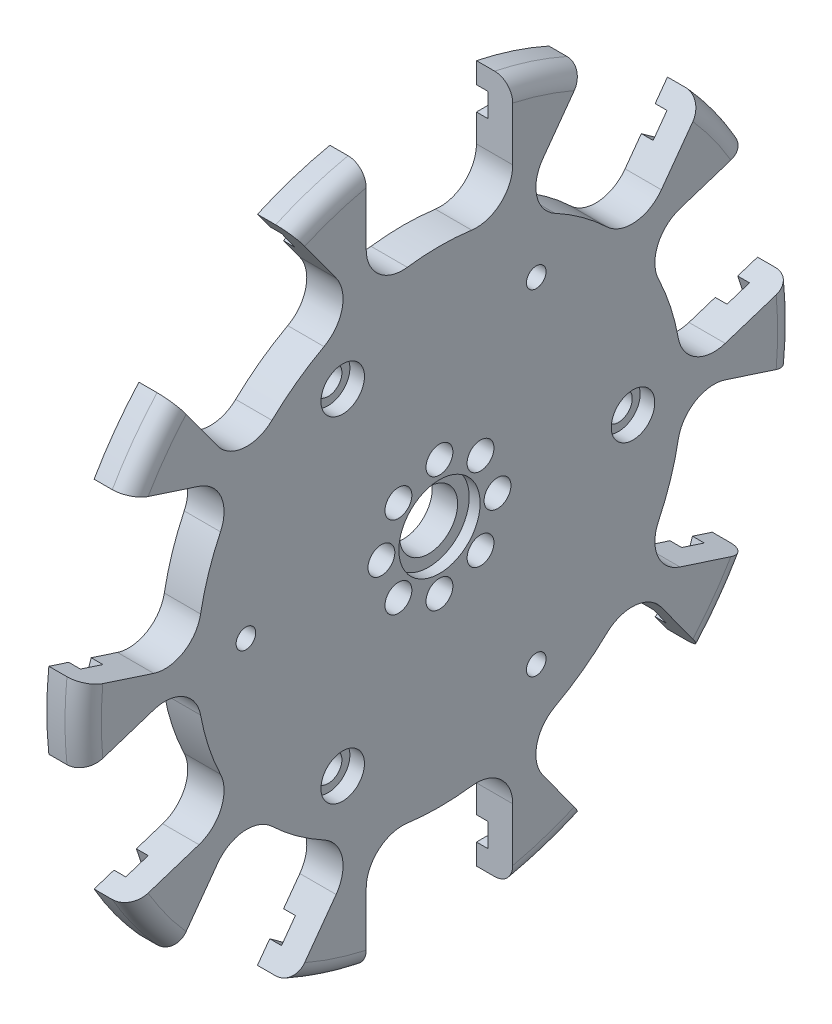
from build123d import *

# Parameters (mm, degrees)
SKETCH1_R           = 4
SKETCH1_R_2         = 1.85
SKETCH1_R_3         = 1.89865
SKETCH1_R_4         = 1.35255
BOSS_EXTRUDE1_DEPTH = 5
FILLET1_R           = 2.5
SKETCH2_W           = 2.7686
SKETCH2_H           = 3.2512
CUT_EXTRUDE1_DEPTH  = 1.6256
SKETCH3_R           = 2.9972
CUT_EXTRUDE2_DEPTH  = 2.0066
SKETCH4_R           = 5.6007
CUT_EXTRUDE3_DEPTH  = 1.4986


with BuildPart() as part:
    # Sketch1 → Boss-Extrude1 (new body)
    with BuildSketch(Plane(origin=(0, 0, 0), x_dir=(0, 0, -1), z_dir=(1, 0, 0))):
        with BuildLine():
            Line((10.0965, 48.061847515), (10.0965, 38.12536489))
            ThreePointArc((10.0965, 38.12536489), (8.38948725, 34.362887652), (4.434006012, 33.16944906))
            ThreePointArc((4.434006012, 33.16944906), (0, 33.4645), (-4.434006012, 33.16944906))
            ThreePointArc((-4.434006012, 33.16944906), (-8.38948725, 34.362887652), (-10.0965, 38.12536489))
            Line((-10.0965, 38.12536489), (-10.0965, 48.061847515))
            ThreePointArc((-10.0965, 48.061847515), (-15.176102709, 46.707241466), (-20.081805084, 44.817425221))
            Line((-20.081805084, 44.817425221), (-14.241287137, 36.778641913))
            ThreePointArc((-14.241287137, 36.778641913), (-13.410760828, 32.731376966), (-15.909326767, 29.440891326))
            ThreePointArc((-15.909326767, 29.440891326), (-19.669939575, 27.073349208), (-23.083699201, 24.228404641))
            ThreePointArc((-23.083699201, 24.228404641), (-26.985236347, 22.868943206), (-30.577767304, 24.909494313))
            Line((-30.577767304, 24.909494313), (-36.418285251, 32.948277621))
            ThreePointArc((-36.418285251, 32.948277621), (-39.731552709, 28.866662747), (-42.589543181, 24.45426978))
            Line((-42.589543181, 24.45426978), (-33.139386631, 21.383727785))
            ThreePointArc((-33.139386631, 21.383727785), (-30.088554085, 18.597592778), (-30.175837459, 14.466913765))
            ThreePointArc((-30.175837459, 14.466913765), (-31.82663079, 10.341099208), (-32.916203881, 6.032933143))
            ThreePointArc((-32.916203881, 6.032933143), (-35.273542354, 2.639839742), (-39.379366799, 2.179043551))
            Line((-39.379366799, 2.179043551), (-48.829523348, 5.249585546))
            ThreePointArc((-48.829523348, 5.249585546), (-49.1109, 0), (-48.829523348, -5.249585546))
            Line((-48.829523348, -5.249585546), (-39.379366799, -2.179043551))
            ThreePointArc((-39.379366799, -2.179043551), (-35.273542354, -2.639839742), (-32.916203881, -6.032933143))
            ThreePointArc((-32.916203881, -6.032933143), (-31.82663079, -10.341099208), (-30.175837459, -14.466913765))
            ThreePointArc((-30.175837459, -14.466913765), (-30.088554085, -18.597592778), (-33.139386631, -21.383727785))
            Line((-33.139386631, -21.383727785), (-42.589543181, -24.45426978))
            ThreePointArc((-42.589543181, -24.45426978), (-39.731552709, -28.866662747), (-36.418285251, -32.948277621))
            Line((-36.418285251, -32.948277621), (-30.577767304, -24.909494313))
            ThreePointArc((-30.577767304, -24.909494313), (-26.985236347, -22.868943206), (-23.083699201, -24.228404641))
            ThreePointArc((-23.083699201, -24.228404641), (-19.669939575, -27.073349208), (-15.909326767, -29.440891326))
            ThreePointArc((-15.909326767, -29.440891326), (-13.410760828, -32.731376966), (-14.241287137, -36.778641913))
            Line((-14.241287137, -36.778641913), (-20.081805084, -44.817425221))
            ThreePointArc((-20.081805084, -44.817425221), (-15.176102709, -46.707241466), (-10.0965, -48.061847515))
            Line((-10.0965, -48.061847515), (-10.0965, -38.12536489))
            ThreePointArc((-10.0965, -38.12536489), (-8.38948725, -34.362887652), (-4.434006012, -33.16944906))
            ThreePointArc((-4.434006012, -33.16944906), (0, -33.4645), (4.434006012, -33.16944906))
            ThreePointArc((4.434006012, -33.16944906), (8.38948725, -34.362887652), (10.0965, -38.12536489))
            Line((10.0965, -38.12536489), (10.0965, -48.061847515))
            ThreePointArc((10.0965, -48.061847515), (15.176102709, -46.707241466), (20.081805084, -44.817425221))
            Line((20.081805084, -44.817425221), (14.241287137, -36.778641913))
            ThreePointArc((14.241287137, -36.778641913), (13.410760828, -32.731376966), (15.909326767, -29.440891326))
            ThreePointArc((15.909326767, -29.440891326), (19.669939575, -27.073349208), (23.083699201, -24.228404641))
            ThreePointArc((23.083699201, -24.228404641), (26.985236347, -22.868943206), (30.577767304, -24.909494313))
            Line((30.577767304, -24.909494313), (36.418285251, -32.948277621))
            ThreePointArc((36.418285251, -32.948277621), (39.731552709, -28.866662747), (42.589543181, -24.45426978))
            Line((42.589543181, -24.45426978), (33.139386631, -21.383727785))
            ThreePointArc((33.139386631, -21.383727785), (30.088554085, -18.597592778), (30.175837459, -14.466913765))
            ThreePointArc((30.175837459, -14.466913765), (31.82663079, -10.341099208), (32.916203881, -6.032933143))
            ThreePointArc((32.916203881, -6.032933143), (35.273542354, -2.639839742), (39.379366799, -2.179043551))
            Line((39.379366799, -2.179043551), (48.829523348, -5.249585546))
            ThreePointArc((48.829523348, -5.249585546), (49.1109, 0), (48.829523348, 5.249585546))
            Line((48.829523348, 5.249585546), (39.379366799, 2.179043551))
            ThreePointArc((39.379366799, 2.179043551), (35.273542354, 2.639839742), (32.916203881, 6.032933143))
            ThreePointArc((32.916203881, 6.032933143), (31.82663079, 10.341099208), (30.175837459, 14.466913765))
            ThreePointArc((30.175837459, 14.466913765), (30.088554085, 18.597592778), (33.139386631, 21.383727785))
            Line((33.139386631, 21.383727785), (42.589543181, 24.45426978))
            ThreePointArc((42.589543181, 24.45426978), (39.731552709, 28.866662747), (36.418285251, 32.948277621))
            Line((36.418285251, 32.948277621), (30.577767304, 24.909494313))
            ThreePointArc((30.577767304, 24.909494313), (26.985236347, 22.868943206), (23.083699201, 24.228404641))
            ThreePointArc((23.083699201, 24.228404641), (19.669939575, 27.073349208), (15.909326767, 29.440891326))
            ThreePointArc((15.909326767, 29.440891326), (13.410760828, 32.731376966), (14.241287137, 36.778641913))
            Line((14.241287137, 36.778641913), (20.081805084, 44.817425221))
            ThreePointArc((20.081805084, 44.817425221), (15.176102709, 46.707241466), (10.0965, 48.061847515))
        make_face()
        Circle(SKETCH1_R, mode=Mode.SUBTRACT)
        with Locations((0, 8)):
            Circle(SKETCH1_R_2, mode=Mode.SUBTRACT)
        with Locations((5.656854249, 5.656854249)):
            Circle(SKETCH1_R_2, mode=Mode.SUBTRACT)
        with Locations((8, 0)):
            Circle(SKETCH1_R_2, mode=Mode.SUBTRACT)
        with Locations((5.656854249, -5.656854249)):
            Circle(SKETCH1_R_2, mode=Mode.SUBTRACT)
        with Locations((0, -8)):
            Circle(SKETCH1_R_2, mode=Mode.SUBTRACT)
        with Locations((-5.656854249, -5.656854249)):
            Circle(SKETCH1_R_2, mode=Mode.SUBTRACT)
        with Locations((-8, 0)):
            Circle(SKETCH1_R_2, mode=Mode.SUBTRACT)
        with Locations((-5.656854249, 5.656854249)):
            Circle(SKETCH1_R_2, mode=Mode.SUBTRACT)
        with Locations((26.67, 0)):
            Circle(SKETCH1_R_3, mode=Mode.SUBTRACT)
        with Locations((-26.67, 0)):
            Circle(SKETCH1_R_4, mode=Mode.SUBTRACT)
        with Locations((-13.335, -23.096897519)):
            Circle(SKETCH1_R_3, mode=Mode.SUBTRACT)
        with Locations((13.335, 23.096897519)):
            Circle(SKETCH1_R_4, mode=Mode.SUBTRACT)
        with Locations((-13.335, 23.096897519)):
            Circle(SKETCH1_R_3, mode=Mode.SUBTRACT)
        with Locations((13.335, -23.096897519)):
            Circle(SKETCH1_R_4, mode=Mode.SUBTRACT)
    extrude(amount=BOSS_EXTRUDE1_DEPTH)

    # Fillet1
    fillet1_edges = [part.edges().sort_by_distance(p)[0] for p in [
        (5, 46.707241466, 15.176102709),
        (5, -46.707241466, -15.176102709),
        (5, -28.866662747, -39.731552709),
        (5, 0, -49.1109),
        (5, 28.866662747, -39.731552709),
        (5, 46.707241466, -15.176102709),
        (5, 28.866662747, 39.731552709),
        (5, 0, 49.1109),
        (5, -28.866662747, 39.731552709),
        (5, -46.707241466, 15.176102709),
    ]]
    fillet(fillet1_edges, radius=FILLET1_R)

    # Sketch2 → Cut-Extrude1 (cut)
    with BuildSketch(Plane.ZY):
        with Locations((-11.4808, 43.561)):
            Rectangle(SKETCH2_W, SKETCH2_H)
        with Locations((11.4808, 43.561)):
            Rectangle(SKETCH2_W, SKETCH2_H)
        Polygon((16.151932547, 44.118643367), (18.391776998, 42.491301118), (16.480769585, 39.861025066), (14.240925135, 41.488367315), align=None)
        Polygon((34.728257165, 30.622153518), (32.817249753, 27.991877466), (35.057094203, 26.364535217), (36.968101616, 28.994811269), align=None)
        Polygon((38.999475845, 26.198864506), (39.855020296, 23.565769435), (36.76294535, 22.561093383), (35.907400899, 25.194188454), align=None)
        Polygon((46.095000463, 4.361085201), (43.002925517, 3.356409149), (43.858469968, 0.723314078), (46.950544914, 1.72799013), align=None)
        Polygon((46.950544914, -1.72799013), (46.095000463, -4.361085201), (43.002925517, -3.356409149), (43.858469968, -0.723314078), align=None)
        Polygon((39.855020296, -23.565769435), (36.76294535, -22.561093383), (35.907400899, -25.194188454), (38.999475845, -26.198864506), align=None)
        Polygon((36.968101616, -28.994811269), (34.728257165, -30.622153518), (32.817249753, -27.991877466), (35.057094203, -26.364535217), align=None)
        Polygon((18.391776998, -42.491301118), (16.480769585, -39.861025066), (14.240925135, -41.488367315), (16.151932547, -44.118643367), align=None)
        with Locations((11.4808, -43.561)):
            Rectangle(SKETCH2_W, SKETCH2_H)
        with Locations((-11.4808, -43.561)):
            Rectangle(SKETCH2_W, SKETCH2_H)
        Polygon((-16.151932547, -44.118643367), (-18.391776998, -42.491301118), (-16.480769585, -39.861025066), (-14.240925135, -41.488367315), align=None)
        Polygon((-34.728257165, -30.622153518), (-32.817249753, -27.991877466), (-35.057094203, -26.364535217), (-36.968101616, -28.994811269), align=None)
        Polygon((-38.999475845, -26.198864506), (-39.855020296, -23.565769435), (-36.76294535, -22.561093383), (-35.907400899, -25.194188454), align=None)
        Polygon((-46.095000463, -4.361085201), (-43.002925517, -3.356409149), (-43.858469968, -0.723314078), (-46.950544914, -1.72799013), align=None)
        Polygon((-46.950544914, 1.72799013), (-46.095000463, 4.361085201), (-43.002925517, 3.356409149), (-43.858469968, 0.723314078), align=None)
        Polygon((-39.855020296, 23.565769435), (-36.76294535, 22.561093383), (-35.907400899, 25.194188454), (-38.999475845, 26.198864506), align=None)
        Polygon((-36.968101616, 28.994811269), (-34.728257165, 30.622153518), (-32.817249753, 27.991877466), (-35.057094203, 26.364535217), align=None)
        Polygon((-18.391776998, 42.491301118), (-16.480769585, 39.861025066), (-14.240925135, 41.488367315), (-16.151932547, 44.118643367), align=None)
    extrude(amount=-CUT_EXTRUDE1_DEPTH, mode=Mode.SUBTRACT)

    # Sketch3 → Cut-Extrude2 (cut)
    with BuildSketch(Plane(origin=(5, 0, 0), x_dir=(0, 0, -1), z_dir=(1, 0, 0))):
        with Locations((26.67, 0)):
            Circle(SKETCH3_R)
        with Locations((-13.335, -23.096897519)):
            Circle(SKETCH3_R)
        with Locations((-13.335, 23.096897519)):
            Circle(SKETCH3_R)
    extrude(amount=-CUT_EXTRUDE2_DEPTH, mode=Mode.SUBTRACT)

    # Sketch4 → Cut-Extrude3 (cut)
    with BuildSketch(Plane(origin=(5, 0, 0), x_dir=(0, 0, -1), z_dir=(1, 0, 0))):
        Circle(SKETCH4_R)
    extrude(amount=-CUT_EXTRUDE3_DEPTH, mode=Mode.SUBTRACT)


solid = part.part
